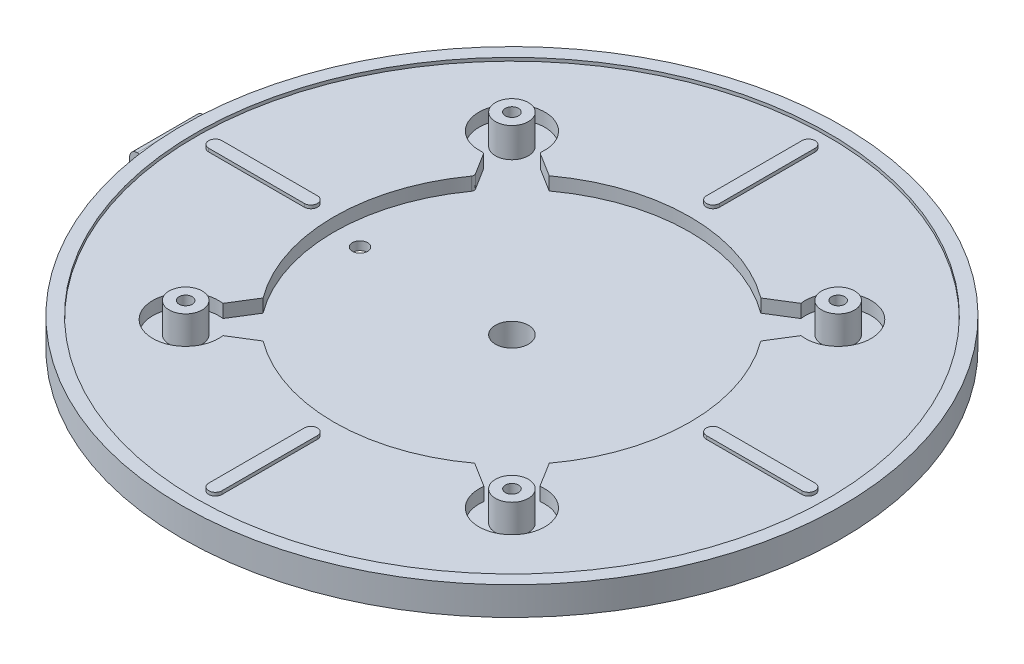
from build123d import *

# Parameters (mm, degrees)
SKETCH1_R                = 50
BOSS_EXTRUDE1_DEPTH      = 4.3
SKETCH3_R                = 48
CUT_EXTRUDE1_DEPTH       = 0.5
BOSS_EXTRUDE2_DEPTH      = 0.5
CIRPATTERN1_COUNT        = 4
CUT_EXTRUDE2_DEPTH       = 2
SKETCH6_R                = 2.5
BOSS_EXTRUDE3_DEPTH      = 4.5
CIRPATTERN2_COUNT        = 4
SKETCH7_R                = 1
CUT_EXTRUDE3_DEPTH       = 7.3
CIRPATTERN3_COUNT        = 4
SKETCH9_R                = 49
CUT_EXTRUDE5_DEPTH       = 0.5
SKETCH10_R               = 44.261614154
CUT_EXTRUDE10_DEPTH      = 1.8
SKETCH12_R               = 18
BOSS_EXTRUDE4_DEPTH      = 4.2
SKETCH13_R               = 2.5
CUT_EXTRUDE11_DEPTH      = 11
BOSS_EXTRUDE5_DEPTH      = 5
BOSS_EXTRUDE5_DEPTH_BACK = 5
SKETCH15_W               = 10
SKETCH15_H               = 2.3
BOSS_EXTRUDE6_DEPTH      = 1
SKETCH16_R               = 1.15
CUT_EXTRUDE12_DEPTH      = 6.5


with BuildPart() as part:
    # Sketch1 → Boss-Extrude1 (new body)
    with BuildSketch(Plane(origin=(0, 0, 0), x_dir=(1, 0, 0), z_dir=(0, 1, 0))):
        Circle(SKETCH1_R)
    extrude(amount=BOSS_EXTRUDE1_DEPTH)

    # Sketch3 → Cut-Extrude1 (cut)
    with BuildSketch(Plane(origin=(0, 4.3, 0), x_dir=(1, 0, 0), z_dir=(0, 1, 0))):
        Circle(SKETCH3_R)
    extrude(amount=-CUT_EXTRUDE1_DEPTH, mode=Mode.SUBTRACT)

    # Sketch4 → Boss-Extrude2 (add)
    with BuildSketch(Plane(origin=(0, 3.8, 0), x_dir=(1, 0, 0), z_dir=(0, 1, 0))):
        with BuildLine():
            Line((30.5, 1), (45, 1))
            ThreePointArc((45, 1), (46, 0), (45, -1))
            Line((45, -1), (30.5, -1))
            ThreePointArc((30.5, -1), (29.5, 0), (30.5, 1))
        make_face()
    boss_extrude2 = extrude(amount=BOSS_EXTRUDE2_DEPTH)

    # CirPattern1: Boss-Extrude2 ×4 about axis
    cirpattern1_axis = Axis((0, 0, 0), (0, 1, 0))
    for i in range(1, CIRPATTERN1_COUNT):
        add(boss_extrude2.rotate(cirpattern1_axis, i * 360 / CIRPATTERN1_COUNT))

    # Sketch5 → Cut-Extrude2 (cut)
    with BuildSketch(Plane(origin=(0, 3.8, 0), x_dir=(1, 0, 0), z_dir=(0, 1, 0))):
        with BuildLine():
            Line((19.798989873, -24.04163056), (16.052780464, -21.709634713))
            ThreePointArc((16.052780464, -21.709634713), (0, -27), (-16.052780464, -21.709634713))
            Line((-16.052780464, -21.709634713), (-19.798989873, -24.04163056))
            ThreePointArc((-19.798989873, -24.04163056), (-28.284271247, -28.284271247), (-24.04163056, -19.798989873))
            Line((-24.04163056, -19.798989873), (-21.709634713, -16.052780464))
            ThreePointArc((-21.709634713, -16.052780464), (-26.999482486, -0.167169073), (-21.906746352, 15.78272677))
            ThreePointArc((-21.906746352, 15.78272677), (-21.81271178, 16.058121718), (-21.887950444, 16.339233833))
            Line((-21.887950444, 16.339233833), (-23.875025498, 19.531348979))
            ThreePointArc((-23.875025498, 19.531348979), (-24.074792266, 19.713775112), (-24.34034148, 19.765443971))
            ThreePointArc((-24.34034148, 19.765443971), (-28.284271247, 28.284271247), (-19.765443971, 24.34034148))
            ThreePointArc((-19.765443971, 24.34034148), (-19.713775112, 24.074792266), (-19.531348979, 23.875025498))
            Line((-19.531348979, 23.875025498), (-16.052780464, 21.709634713))
            ThreePointArc((-16.052780464, 21.709634713), (0, 27), (16.052780464, 21.709634713))
            Line((16.052780464, 21.709634713), (19.798989873, 24.04163056))
            ThreePointArc((19.798989873, 24.04163056), (28.284271247, 28.284271247), (24.04163056, 19.798989873))
            Line((24.04163056, 19.798989873), (21.709634713, 16.052780464))
            ThreePointArc((21.709634713, 16.052780464), (27, 0), (21.709634713, -16.052780464))
            Line((21.709634713, -16.052780464), (24.04163056, -19.798989873))
            ThreePointArc((24.04163056, -19.798989873), (28.284271247, -28.284271247), (19.798989873, -24.04163056))
        make_face()
    extrude(amount=-CUT_EXTRUDE2_DEPTH, mode=Mode.SUBTRACT)

    # Sketch6 → Boss-Extrude3 (add)
    with BuildSketch(Plane(origin=(0, 1.8, 0), x_dir=(1, 0, 0), z_dir=(0, 1, 0))):
        with Locations((24.748737342, 24.748737342)):
            Circle(SKETCH6_R)
    boss_extrude3 = extrude(amount=BOSS_EXTRUDE3_DEPTH)

    # CirPattern2: Boss-Extrude3 ×4 about axis
    cirpattern2_axis = Axis((0, 0, 0), (0, 1, 0))
    for i in range(1, CIRPATTERN2_COUNT):
        add(boss_extrude3.rotate(cirpattern2_axis, i * 360 / CIRPATTERN2_COUNT))

    # Sketch7 → Cut-Extrude3 (cut, through all)
    with BuildSketch(Plane(origin=(0, 6.3, 0), x_dir=(1, 0, 0), z_dir=(0, 1, 0))):
        with Locations((24.748737342, 24.748737342)):
            Circle(SKETCH7_R)
    cut_extrude3 = extrude(amount=-CUT_EXTRUDE3_DEPTH, mode=Mode.SUBTRACT)

    # CirPattern3: Cut-Extrude3 ×4 about axis
    cirpattern3_axis = Axis((0, 0, 0), (0, 1, 0))
    for i in range(1, CIRPATTERN3_COUNT):
        add(cut_extrude3.rotate(cirpattern3_axis, i * 360 / CIRPATTERN3_COUNT), mode=Mode.SUBTRACT)

    # Sketch9 → Cut-Extrude5 (cut)
    with BuildSketch(Plane.XZ):
        Circle(SKETCH9_R)
    extrude(amount=-CUT_EXTRUDE5_DEPTH, mode=Mode.SUBTRACT)

    # Sketch10 → Cut-Extrude10 (cut)
    with BuildSketch(Plane.XZ.offset(-0.5)):
        Circle(SKETCH10_R)
        with BuildLine():
            Line((16.446582493, 23.439915657), (18.575096394, 24.989489579))
            ThreePointArc((18.575096394, 24.989489579), (18.714612745, 25.145078668), (18.778348721, 25.34410254))
            ThreePointArc((18.778348721, 25.34410254), (28.991378029, 28.991378029), (25.34410254, 18.778348721))
            ThreePointArc((25.34410254, 18.778348721), (25.145078668, 18.714612745), (24.989489579, 18.575096394))
            Line((24.989489579, 18.575096394), (23.439915657, 16.446582493))
            ThreePointArc((23.439915657, 16.446582493), (23.34421409, 16.160770025), (23.430181579, 15.871880517))
            ThreePointArc((23.430181579, 15.871880517), (28.3, 0), (23.430181579, -15.871880517))
            ThreePointArc((23.430181579, -15.871880517), (23.34421409, -16.160770025), (23.439915657, -16.446582493))
            Line((23.439915657, -16.446582493), (24.989489579, -18.575096394))
            ThreePointArc((24.989489579, -18.575096394), (25.145078668, -18.714612745), (25.34410254, -18.778348721))
            ThreePointArc((25.34410254, -18.778348721), (28.991378029, -28.991378029), (18.778348721, -25.34410254))
            ThreePointArc((18.778348721, -25.34410254), (18.714612745, -25.145078668), (18.575096394, -24.989489579))
            Line((18.575096394, -24.989489579), (16.446582493, -23.439915657))
            ThreePointArc((16.446582493, -23.439915657), (16.160770025, -23.34421409), (15.871880517, -23.430181579))
            ThreePointArc((15.871880517, -23.430181579), (0, -28.3), (-15.871880517, -23.430181579))
            ThreePointArc((-15.871880517, -23.430181579), (-16.160770025, -23.34421409), (-16.446582493, -23.439915657))
            Line((-16.446582493, -23.439915657), (-18.575096394, -24.989489579))
            ThreePointArc((-18.575096394, -24.989489579), (-18.714612745, -25.145078668), (-18.778348721, -25.34410254))
            ThreePointArc((-18.778348721, -25.34410254), (-28.991378029, -28.991378029), (-25.34410254, -18.778348721))
            ThreePointArc((-25.34410254, -18.778348721), (-25.145078668, -18.714612745), (-24.989489579, -18.575096394))
            Line((-24.989489579, -18.575096394), (-23.439915657, -16.446582493))
            ThreePointArc((-23.439915657, -16.446582493), (-23.34421409, -16.160770025), (-23.430181579, -15.871880517))
            ThreePointArc((-23.430181579, -15.871880517), (-28.3, 0), (-23.430181579, 15.871880517))
            ThreePointArc((-23.430181579, 15.871880517), (-23.34421409, 16.160770025), (-23.439915657, 16.446582493))
            Line((-23.439915657, 16.446582493), (-24.989489579, 18.575096394))
            ThreePointArc((-24.989489579, 18.575096394), (-25.145078668, 18.714612745), (-25.34410254, 18.778348721))
            ThreePointArc((-25.34410254, 18.778348721), (-28.991378029, 28.991378029), (-18.778348721, 25.34410254))
            ThreePointArc((-18.778348721, 25.34410254), (-18.714612745, 25.145078668), (-18.575096394, 24.989489579))
            Line((-18.575096394, 24.989489579), (-16.446582493, 23.439915657))
            ThreePointArc((-16.446582493, 23.439915657), (-16.160770025, 23.34421409), (-15.871880517, 23.430181579))
            ThreePointArc((-15.871880517, 23.430181579), (0, 28.3), (15.871880517, 23.430181579))
            ThreePointArc((15.871880517, 23.430181579), (16.160770025, 23.34421409), (16.446582493, 23.439915657))
        make_face(mode=Mode.SUBTRACT)
    extrude(amount=-CUT_EXTRUDE10_DEPTH, mode=Mode.SUBTRACT)

    # Sketch12 → Boss-Extrude4 (add)
    with BuildSketch(Plane.XZ.offset(-0.5)):
        Circle(SKETCH12_R)
    extrude(amount=BOSS_EXTRUDE4_DEPTH)

    # Sketch13 → Cut-Extrude11 (cut, through all)
    with BuildSketch(Plane.XZ.offset(3.7)):
        Circle(SKETCH13_R)
    extrude(amount=-CUT_EXTRUDE11_DEPTH, mode=Mode.SUBTRACT)

    # Sketch16 → Cut-Extrude12 (cut, through all)
    with BuildSketch(Plane(origin=(0, 1.8, 0), x_dir=(1, 0, 0), z_dir=(0, 1, 0))):
        with Locations((-23.05, 0)):
            Circle(SKETCH16_R)
    extrude(amount=-CUT_EXTRUDE12_DEPTH, mode=Mode.SUBTRACT)


with BuildPart() as body_2:
    # Sketch14 → Boss-Extrude5 (new body, two sides)
    with BuildSketch(Plane.XY) as boss_extrude5_sk:
        with BuildLine():
            Line((-51.85, 2.3), (-50, 2.3))
            Line((-50, 2.3), (-50, 0))
            Line((-50, 0), (-50.2, 0))
            ThreePointArc((-50.2, 0), (-50.553553391, -0.146446609), (-50.7, -0.5))
            Line((-50.7, -0.5), (-50.7, -2.55))
            ThreePointArc((-50.7, -2.55), (-51.85, -3.7), (-53, -2.55))
            Line((-53, -2.55), (-53, 1.15))
            ThreePointArc((-53, 1.15), (-52.663172798, 1.963172798), (-51.85, 2.3))
        make_face()
    extrude(amount=BOSS_EXTRUDE5_DEPTH)
    extrude(boss_extrude5_sk.sketch, amount=-BOSS_EXTRUDE5_DEPTH_BACK)

    # Sketch15 → Boss-Extrude6 (add)
    with BuildSketch(Plane(origin=(-50, 0, 0), x_dir=(0, 0, -1), z_dir=(1, 0, 0))):
        with Locations((0, 1.15)):
            Rectangle(SKETCH15_W, SKETCH15_H)
    extrude(amount=BOSS_EXTRUDE6_DEPTH)


solid = Compound([part.part, body_2.part])
